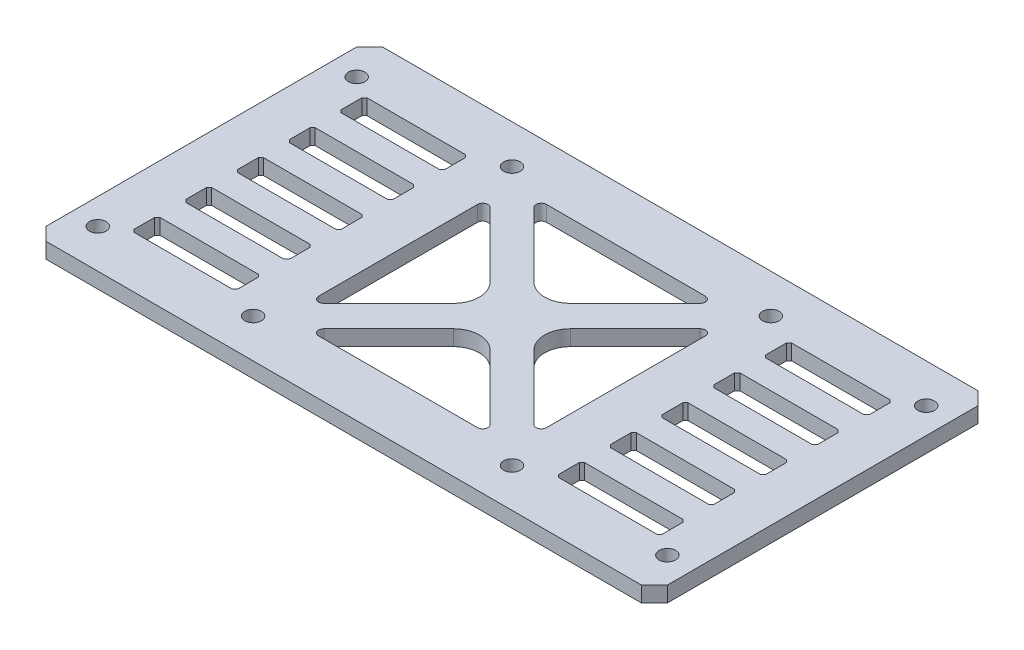
from build123d import *

# Parameters (mm, degrees)
SKETCH_1_W          = 120
SKETCH_1_H          = 65
SKETCH_1_R          = 1.6
EXTRUDE_1_DEPTH     = 3
CUT_EXTRUDE_1_REACH = 5
SKETCH_2_R          = 1.6
CUT_EXTRUDE_2_REACH = 5
CUT_EXTRUDE_3_DEPTH = 3
CHAMFER_1_SIZE      = 2.5


with BuildPart() as part:
    # 草图1 → 凸台-拉伸1 (new body)
    with BuildSketch(Plane(origin=(0, 0, 0), x_dir=(1, 0, 0), z_dir=(0, 1, 0))):
        Rectangle(SKETCH_1_W, SKETCH_1_H)
        with Locations((-25, 25)):
            Circle(SKETCH_1_R, mode=Mode.SUBTRACT)
        with Locations((25, 25)):
            Circle(SKETCH_1_R, mode=Mode.SUBTRACT)
        with Locations((25, -25)):
            Circle(SKETCH_1_R, mode=Mode.SUBTRACT)
        with Locations((-25, -25)):
            Circle(SKETCH_1_R, mode=Mode.SUBTRACT)
    extrude(amount=EXTRUDE_1_DEPTH)

    # 草图2 → 切除-拉伸1 (cut, up to next)
    with BuildSketch(Plane(origin=(0, 3, 0), x_dir=(1, 0, 0), z_dir=(0, 1, 0)), mode=Mode.PRIVATE) as cut_extrude_1_sk1:
        with Locations((55, 25)):
            Circle(SKETCH_2_R)
    cut_extrude_1_tool1 = extrude(cut_extrude_1_sk1.sketch, amount=-CUT_EXTRUDE_1_REACH, mode=Mode.PRIVATE) & part.part
    add(cut_extrude_1_tool1.solids().sort_by_distance((55, 3, -25))[0], mode=Mode.SUBTRACT)
    # 草图2 → 切除-拉伸1 (cut, up to next)
    with BuildSketch(Plane(origin=(0, 3, 0), x_dir=(1, 0, 0), z_dir=(0, 1, 0)), mode=Mode.PRIVATE) as cut_extrude_1_sk2:
        with Locations((55, -25)):
            Circle(SKETCH_2_R)
    cut_extrude_1_tool2 = extrude(cut_extrude_1_sk2.sketch, amount=-CUT_EXTRUDE_1_REACH, mode=Mode.PRIVATE) & part.part
    add(cut_extrude_1_tool2.solids().sort_by_distance((55, 3, 25))[0], mode=Mode.SUBTRACT)
    # 草图2 → 切除-拉伸1 (cut, up to next)
    with BuildSketch(Plane(origin=(0, 3, 0), x_dir=(1, 0, 0), z_dir=(0, 1, 0)), mode=Mode.PRIVATE) as cut_extrude_1_sk3:
        with Locations((-55, -25)):
            Circle(SKETCH_2_R)
    cut_extrude_1_tool3 = extrude(cut_extrude_1_sk3.sketch, amount=-CUT_EXTRUDE_1_REACH, mode=Mode.PRIVATE) & part.part
    add(cut_extrude_1_tool3.solids().sort_by_distance((-55, 3, 25))[0], mode=Mode.SUBTRACT)
    # 草图2 → 切除-拉伸1 (cut, up to next)
    with BuildSketch(Plane(origin=(0, 3, 0), x_dir=(1, 0, 0), z_dir=(0, 1, 0)), mode=Mode.PRIVATE) as cut_extrude_1_sk4:
        with Locations((-55, 25)):
            Circle(SKETCH_2_R)
    cut_extrude_1_tool4 = extrude(cut_extrude_1_sk4.sketch, amount=-CUT_EXTRUDE_1_REACH, mode=Mode.PRIVATE) & part.part
    add(cut_extrude_1_tool4.solids().sort_by_distance((-55, 3, -25))[0], mode=Mode.SUBTRACT)

    # 草图3 → 切除-拉伸2 (cut, up to next)
    with BuildSketch(Plane(origin=(0, 3, 0), x_dir=(1, 0, 0), z_dir=(0, 1, 0)), mode=Mode.PRIVATE) as cut_extrude_2_sk1:
        with BuildLine():
            Line((-22, 15.343145751), (-22, -15.343145751))
            ThreePointArc((-22, -15.343145751), (-21.382683432, -16.267025283), (-20.292893219, -16.050252532))
            Line((-20.292893219, -16.050252532), (-7.778174593, -3.535533906))
            ThreePointArc((-7.778174593, -3.535533906), (-6.313708499, 0), (-7.778174593, 3.535533906))
            Line((-7.778174593, 3.535533906), (-20.292893219, 16.050252532))
            ThreePointArc((-20.292893219, 16.050252532), (-21.382683432, 16.267025283), (-22, 15.343145751))
        make_face()
    cut_extrude_2_tool1 = extrude(cut_extrude_2_sk1.sketch, amount=-CUT_EXTRUDE_2_REACH, mode=Mode.PRIVATE) & part.part
    add(cut_extrude_2_tool1.solids().sort_by_distance((-16.215858, 3, 0))[0], mode=Mode.SUBTRACT)
    # 草图3 → 切除-拉伸2 (cut, up to next)
    with BuildSketch(Plane(origin=(0, 3, 0), x_dir=(1, 0, 0), z_dir=(0, 1, 0)), mode=Mode.PRIVATE) as cut_extrude_2_sk2:
        with BuildLine():
            Line((15.343145751, 22), (-15.343145751, 22))
            ThreePointArc((-15.343145751, 22), (-16.267025283, 21.382683432), (-16.050252532, 20.292893219))
            Line((-16.050252532, 20.292893219), (-3.535533906, 7.778174593))
            ThreePointArc((-3.535533906, 7.778174593), (0, 6.313708499), (3.535533906, 7.778174593))
            Line((3.535533906, 7.778174593), (16.050252532, 20.292893219))
            ThreePointArc((16.050252532, 20.292893219), (16.267025283, 21.382683432), (15.343145751, 22))
        make_face()
    cut_extrude_2_tool2 = extrude(cut_extrude_2_sk2.sketch, amount=-CUT_EXTRUDE_2_REACH, mode=Mode.PRIVATE) & part.part
    add(cut_extrude_2_tool2.solids().sort_by_distance((0, 3, -16.215858))[0], mode=Mode.SUBTRACT)
    # 草图3 → 切除-拉伸2 (cut, up to next)
    with BuildSketch(Plane(origin=(0, 3, 0), x_dir=(1, 0, 0), z_dir=(0, 1, 0)), mode=Mode.PRIVATE) as cut_extrude_2_sk3:
        with BuildLine():
            Line((22, -15.343145751), (22, 15.343145751))
            ThreePointArc((22, 15.343145751), (21.382683432, 16.267025283), (20.292893219, 16.050252532))
            Line((20.292893219, 16.050252532), (7.778174593, 3.535533906))
            ThreePointArc((7.778174593, 3.535533906), (6.313708499, 0), (7.778174593, -3.535533906))
            Line((7.778174593, -3.535533906), (20.292893219, -16.050252532))
            ThreePointArc((20.292893219, -16.050252532), (21.382683432, -16.267025283), (22, -15.343145751))
        make_face()
    cut_extrude_2_tool3 = extrude(cut_extrude_2_sk3.sketch, amount=-CUT_EXTRUDE_2_REACH, mode=Mode.PRIVATE) & part.part
    add(cut_extrude_2_tool3.solids().sort_by_distance((16.215858, 3, 0))[0], mode=Mode.SUBTRACT)
    # 草图3 → 切除-拉伸2 (cut, up to next)
    with BuildSketch(Plane(origin=(0, 3, 0), x_dir=(1, 0, 0), z_dir=(0, 1, 0)), mode=Mode.PRIVATE) as cut_extrude_2_sk4:
        with BuildLine():
            Line((-15.343145751, -22), (15.343145751, -22))
            ThreePointArc((15.343145751, -22), (16.267025283, -21.382683432), (16.050252532, -20.292893219))
            Line((16.050252532, -20.292893219), (3.535533906, -7.778174593))
            ThreePointArc((3.535533906, -7.778174593), (0, -6.313708499), (-3.535533906, -7.778174593))
            Line((-3.535533906, -7.778174593), (-16.050252532, -20.292893219))
            ThreePointArc((-16.050252532, -20.292893219), (-16.267025283, -21.382683432), (-15.343145751, -22))
        make_face()
    cut_extrude_2_tool4 = extrude(cut_extrude_2_sk4.sketch, amount=-CUT_EXTRUDE_2_REACH, mode=Mode.PRIVATE) & part.part
    add(cut_extrude_2_tool4.solids().sort_by_distance((0, 3, 16.215858))[0], mode=Mode.SUBTRACT)

    # 草图4 → 切除-拉伸3 (cut)
    with BuildSketch(Plane.XZ):
        Polygon((50.5, -2.5), (51, -2), (51, 2), (50.5, 2.5), (31.5, 2.5), (31, 2), (31, -2), (31.5, -2.5), align=None)
        Polygon((50.5, 7.5), (31.5, 7.5), (31, 8), (31, 12), (31.5, 12.5), (50.5, 12.5), (51, 12), (51, 8), align=None)
        Polygon((50.5, 17.5), (31.5, 17.5), (31, 18), (31, 22), (31.5, 22.5), (50.5, 22.5), (51, 22), (51, 18), align=None)
        Polygon((31.5, -17.5), (31, -18), (31, -22), (31.5, -22.5), (50.5, -22.5), (51, -22), (51, -18), (50.5, -17.5), align=None)
        Polygon((31.5, -7.5), (31, -8), (31, -12), (31.5, -12.5), (50.5, -12.5), (51, -12), (51, -8), (50.5, -7.5), align=None)
        Polygon((-50.5, -7.5), (-31.5, -7.5), (-31, -8), (-31, -12), (-31.5, -12.5), (-50.5, -12.5), (-51, -12), (-51, -8), align=None)
        Polygon((-50.5, -17.5), (-31.5, -17.5), (-31, -18), (-31, -22), (-31.5, -22.5), (-50.5, -22.5), (-51, -22), (-51, -18), align=None)
        Polygon((-31.5, 17.5), (-31, 18), (-31, 22), (-31.5, 22.5), (-50.5, 22.5), (-51, 22), (-51, 18), (-50.5, 17.5), align=None)
        Polygon((-31.5, 7.5), (-31, 8), (-31, 12), (-31.5, 12.5), (-50.5, 12.5), (-51, 12), (-51, 8), (-50.5, 7.5), align=None)
        Polygon((-31.5, 2.5), (-31, 2), (-31, -2), (-31.5, -2.5), (-50.5, -2.5), (-51, -2), (-51, 2), (-50.5, 2.5), align=None)
    extrude(amount=-CUT_EXTRUDE_3_DEPTH, mode=Mode.SUBTRACT)

    # 倒角1
    chamfer_1_edges = [part.edges().sort_by_distance(p)[0] for p in [
        (60, 1.5, 32.5),
        (-60, 1.5, 32.5),
        (-60, 1.5, -32.5),
        (60, 1.5, -32.5),
    ]]
    chamfer(chamfer_1_edges, length=CHAMFER_1_SIZE)


solid = part.part
